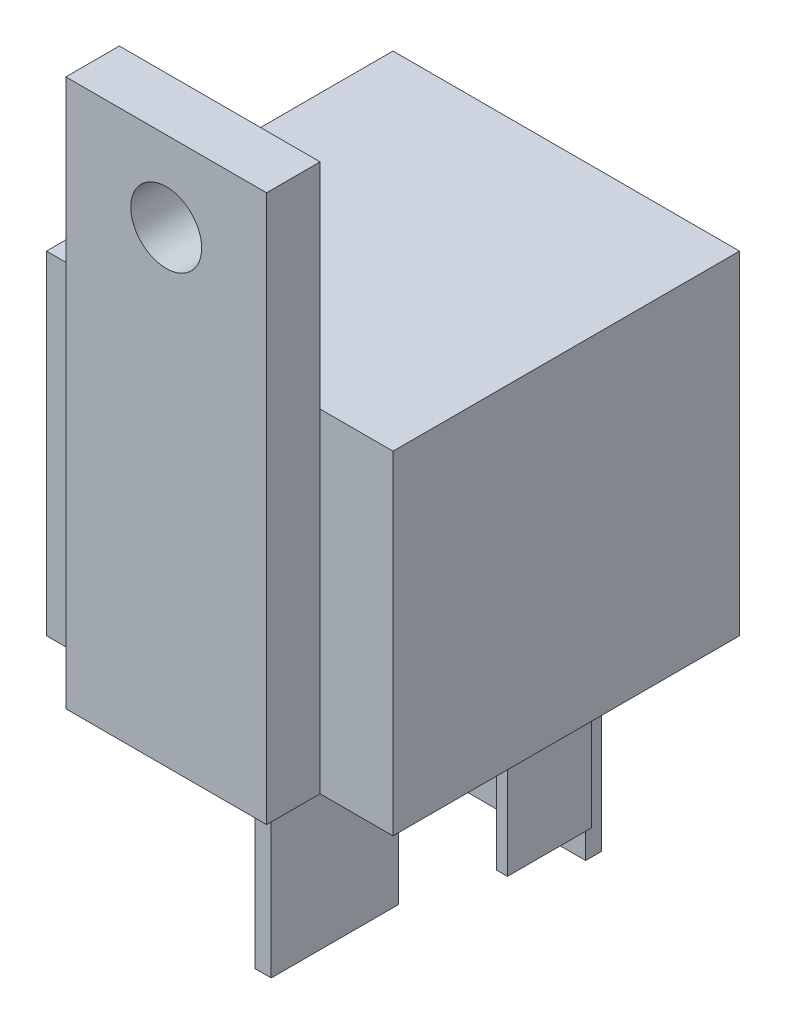
from build123d import *

# Parameters (mm, degrees)
SKETCH1_W           = 25.9
SKETCH1_H           = 25.9
BOSS_EXTRUDE1_DEPTH = 24.9
SKETCH2_W           = 15
SKETCH2_H           = 40.9
SKETCH2_R           = 2.65
BOSS_EXTRUDE2_DEPTH = 4
SKETCH3_W           = 9.5
SKETCH3_H           = 1.2
SKETCH3_W_2         = 0.8
SKETCH3_H_2         = 6.3
SKETCH3_W_3         = 1.2
SKETCH3_H_3         = 9.5
BOSS_EXTRUDE3_DEPTH = 11
SKETCH5_W           = 1.2
SKETCH5_H           = 9.5
SKETCH5_W_2         = 9.5
SKETCH5_H_2         = 1.2
BOSS_EXTRUDE4_DEPTH = 6


with BuildPart() as part:
    # Sketch1 → Boss-Extrude1 (new body)
    with BuildSketch(Plane(origin=(0, 0, 0), x_dir=(1, 0, 0), z_dir=(0, 1, 0))):
        with Locations((12.95, 12.95)):
            Rectangle(SKETCH1_W, SKETCH1_H)
    extrude(amount=BOSS_EXTRUDE1_DEPTH)

    # Sketch2 → Boss-Extrude2 (add)
    with BuildSketch(Plane.XY):
        with Locations((12.95, 20.45)):
            Rectangle(SKETCH2_W, SKETCH2_H)
        with Locations((12.95, 34.9)):
            Circle(SKETCH2_R, mode=Mode.SUBTRACT)
    extrude(amount=BOSS_EXTRUDE2_DEPTH)

    # Sketch3 → Boss-Extrude3 (add)
    with BuildSketch(Plane.XZ):
        with Locations((12.95, -23.2)):
            Rectangle(SKETCH3_W, SKETCH3_H)
        with Locations((21.4, -15.8)):
            Rectangle(SKETCH3_W_2, SKETCH3_H_2)
        with Locations((4.5, -15.8)):
            Rectangle(SKETCH3_W_2, SKETCH3_H_2)
        with Locations((12.95, -8)):
            Rectangle(SKETCH3_W_3, SKETCH3_H_3)
    extrude(amount=BOSS_EXTRUDE3_DEPTH)

    # Sketch5 → Boss-Extrude4 (add)
    with BuildSketch(Plane.XZ.offset(11)):
        with Locations((12.95, -8)):
            Rectangle(SKETCH5_W, SKETCH5_H)
        with Locations((12.95, -23.2)):
            Rectangle(SKETCH5_W_2, SKETCH5_H_2)
    extrude(amount=BOSS_EXTRUDE4_DEPTH)


solid = part.part
